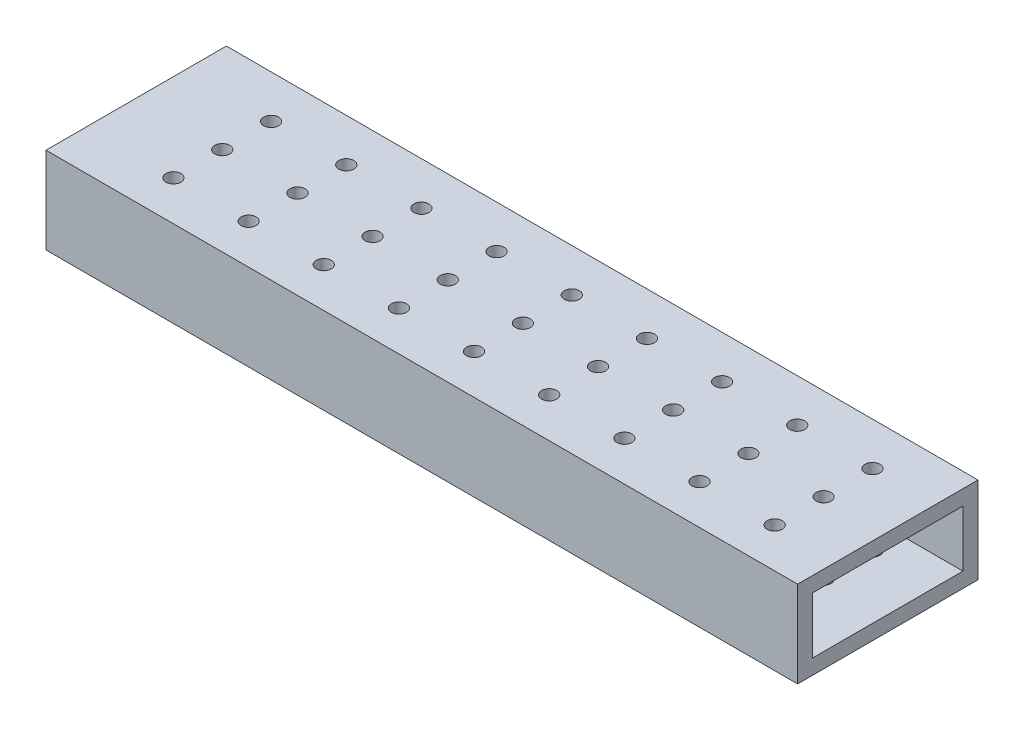
from build123d import *

# Parameters (mm, degrees)
SKETCH1_W           = 48
SKETCH1_H           = 23
SKETCH1_W_2         = 40
SKETCH1_H_2         = 15
EXTRUDE_THIN1_DEPTH = 100
SKETCH2_R           = 2
CUT_EXTRUDE1_DEPTH  = 24


with BuildPart() as part:
    # Sketch1 → Extrude-Thin1 (new body, symmetric)
    with BuildSketch(Plane(origin=(0, 0, 0), x_dir=(0, 0, -1), z_dir=(1, 0, 0))):
        Rectangle(SKETCH1_W, SKETCH1_H)
        Rectangle(SKETCH1_W_2, SKETCH1_H_2, mode=Mode.SUBTRACT)
    extrude(amount=EXTRUDE_THIN1_DEPTH, both=True)

    # Sketch2 → Cut-Extrude1 (cut, through all)
    with BuildSketch(Plane(origin=(0, 11.5, 0), x_dir=(1, 0, 0), z_dir=(0, 1, 0))):
        with Locations((-76.678469137, 12.583133397)):
            Circle(SKETCH2_R)
        with Locations((-56.678469137, 12.583133397)):
            Circle(SKETCH2_R)
        with Locations((-36.678469137, 12.583133397)):
            Circle(SKETCH2_R)
        with Locations((-16.678469137, 12.583133397)):
            Circle(SKETCH2_R)
        with Locations((3.321530863, 12.583133397)):
            Circle(SKETCH2_R)
        with Locations((23.321530863, 12.583133397)):
            Circle(SKETCH2_R)
        with Locations((43.321530863, 12.583133397)):
            Circle(SKETCH2_R)
        with Locations((63.321530863, 12.583133397)):
            Circle(SKETCH2_R)
        with Locations((83.321530863, 12.583133397)):
            Circle(SKETCH2_R)
        with Locations((-56.678469137, -0.416866603)):
            Circle(SKETCH2_R)
        with Locations((-36.678469137, -0.416866603)):
            Circle(SKETCH2_R)
        with Locations((-16.678469137, -0.416866603)):
            Circle(SKETCH2_R)
        with Locations((3.321530863, -0.416866603)):
            Circle(SKETCH2_R)
        with Locations((23.321530863, -0.416866603)):
            Circle(SKETCH2_R)
        with Locations((43.321530863, -0.416866603)):
            Circle(SKETCH2_R)
        with Locations((63.321530863, -0.416866603)):
            Circle(SKETCH2_R)
        with Locations((83.321530863, -0.416866603)):
            Circle(SKETCH2_R)
        with Locations((-56.678469137, -13.416866603)):
            Circle(SKETCH2_R)
        with Locations((-36.678469137, -13.416866603)):
            Circle(SKETCH2_R)
        with Locations((-16.678469137, -13.416866603)):
            Circle(SKETCH2_R)
        with Locations((3.321530863, -13.416866603)):
            Circle(SKETCH2_R)
        with Locations((23.321530863, -13.416866603)):
            Circle(SKETCH2_R)
        with Locations((43.321530863, -13.416866603)):
            Circle(SKETCH2_R)
        with Locations((63.321530863, -13.416866603)):
            Circle(SKETCH2_R)
        with Locations((83.321530863, -13.416866603)):
            Circle(SKETCH2_R)
        with Locations((-76.678469137, -0.416866603)):
            Circle(SKETCH2_R)
        with Locations((-76.678469137, -13.416866603)):
            Circle(SKETCH2_R)
    extrude(amount=-CUT_EXTRUDE1_DEPTH, mode=Mode.SUBTRACT)


solid = part.part
